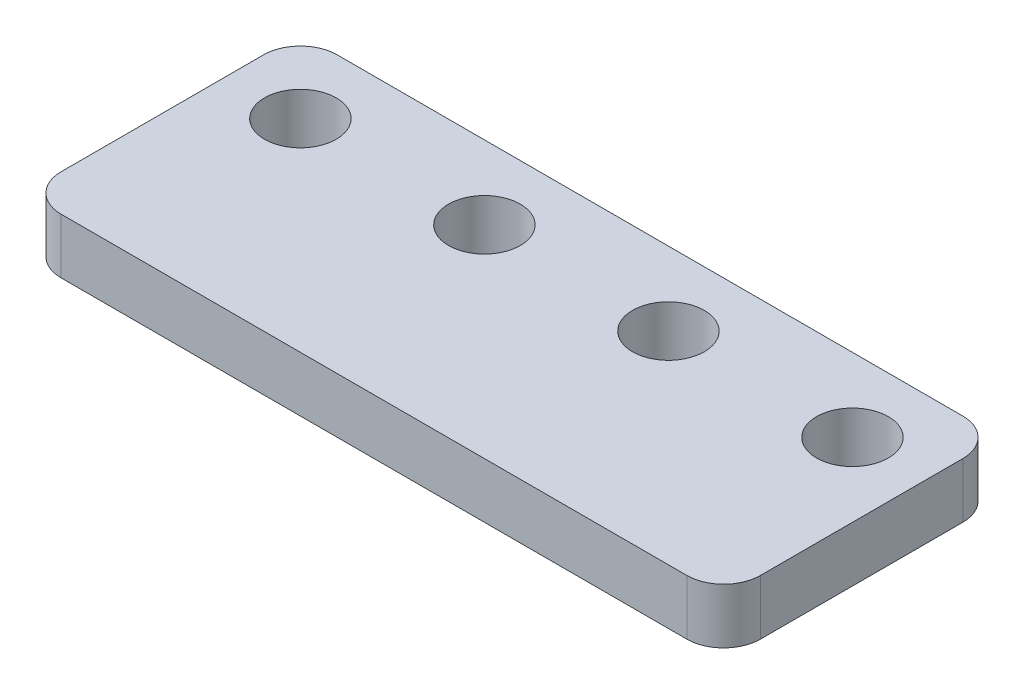
from build123d import *

# Parameters (mm, degrees)
BOSS_EXTRUDE1_DEPTH = 3
SKETCH2_R           = 1.95
CUT_EXTRUDE1_DEPTH  = 4


with BuildPart() as part:
    # Sketch1 → Boss-Extrude1 (new body)
    with BuildSketch(Plane(origin=(0, 0, 0), x_dir=(1, 0, 0), z_dir=(0, 1, 0))):
        with BuildLine():
            Line((-36, 0), (-2, 0))
            ThreePointArc((-2, 0), (-0.585786438, -0.585786438), (0, -2))
            Line((0, -2), (0, -13))
            ThreePointArc((0, -13), (-0.585786438, -14.414213562), (-2, -15))
            Line((-2, -15), (-36, -15))
            ThreePointArc((-36, -15), (-37.414213562, -14.414213562), (-38, -13))
            Line((-38, -13), (-38, -2))
            ThreePointArc((-38, -2), (-37.414213562, -0.585786438), (-36, 0))
        make_face()
    extrude(amount=BOSS_EXTRUDE1_DEPTH)

    # Sketch2 → Cut-Extrude1 (cut, through all)
    with BuildSketch(Plane(origin=(0, 3, 0), x_dir=(1, 0, 0), z_dir=(0, 1, 0))):
        with Locations((-4, -4)):
            Circle(SKETCH2_R)
        with Locations((-14, -4)):
            Circle(SKETCH2_R)
        with Locations((-24, -4)):
            Circle(SKETCH2_R)
        with Locations((-54, -4)):
            Circle(SKETCH2_R)
        with Locations((-34, -4)):
            Circle(SKETCH2_R)
        with Locations((-44, -4)):
            Circle(SKETCH2_R)
    extrude(amount=-CUT_EXTRUDE1_DEPTH, mode=Mode.SUBTRACT)


solid = part.part
